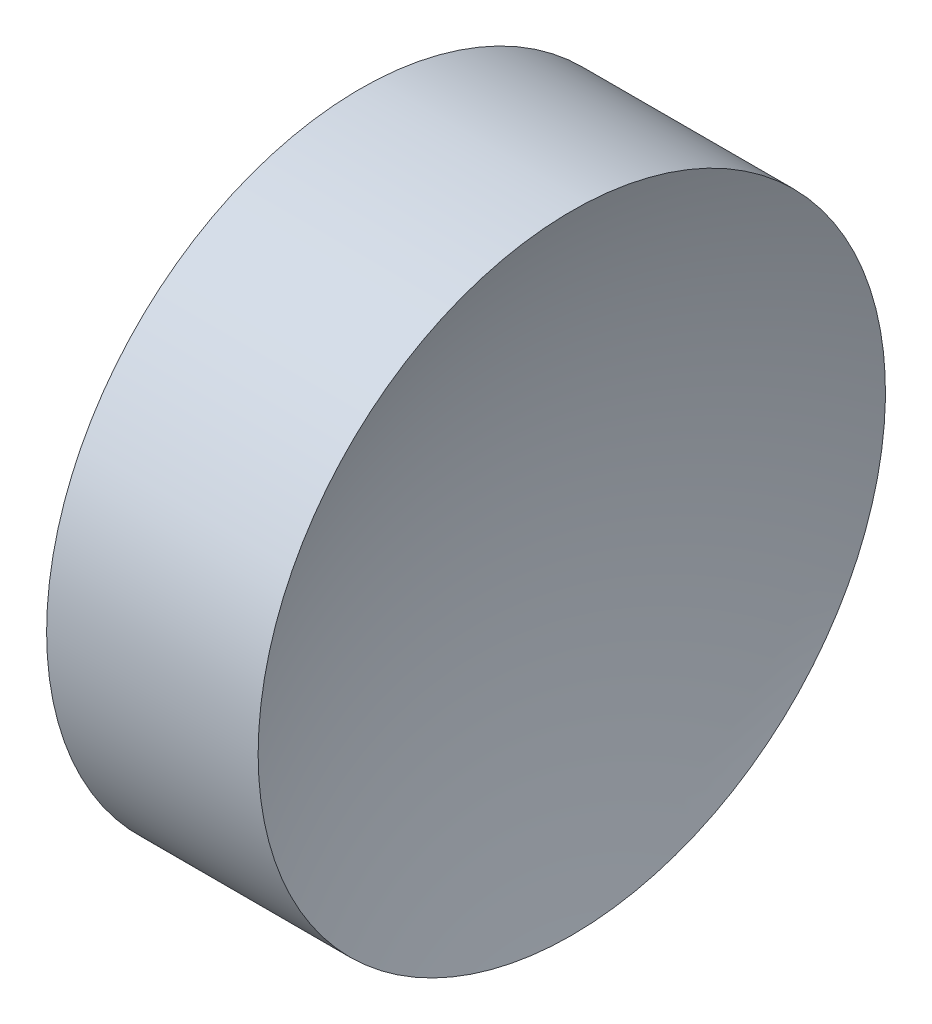
from build123d import *


with BuildPart() as part:
    # 草图1 → 旋转1 (revolve)
    with BuildSketch(Plane.XY, mode=Mode.PRIVATE) as revolve_1_sk:
        with BuildLine():
            Line((22.309268833, 13.031126091), (22.309268833, 16.181126091))
            Line((22.309268833, 16.181126091), (24.433491204, 16.181126091))
            ThreePointArc((24.433491204, 16.181126091), (23.966827126, 14.636753194), (23.809268833, 13.031126091))
            Line((23.809268833, 13.031126091), (22.309268833, 13.031126091))
        make_face()
    revolve(revolve_1_sk.sketch.rotate(Axis((20.684030635, 13.031126091, 0), (1, 0, 0)), 180), axis=Axis((20.684030635, 13.031126091, 0), (1, 0, 0)))  # turned: the seam where the file's is


solid = part.part
